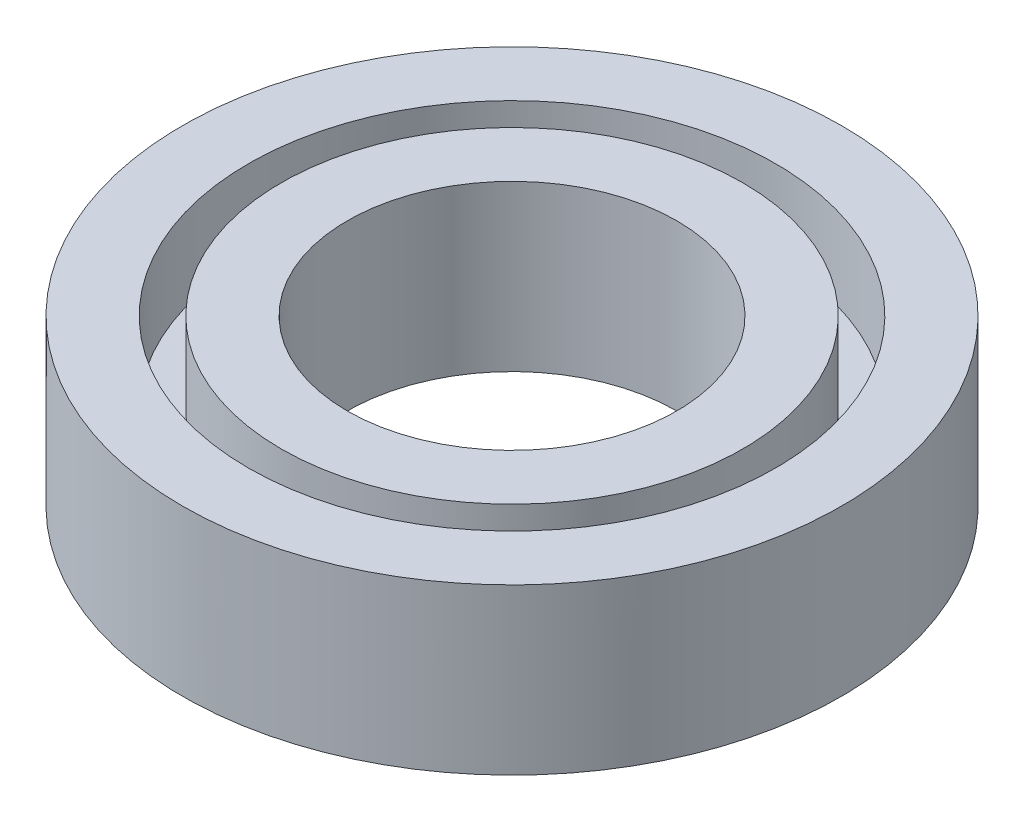
from build123d import *

# Parameters (mm, degrees)
SKETCH1_R           = 4
SKETCH1_R_2         = 2
BOSS_EXTRUDE1_DEPTH = 3
SKETCH2_R           = 3.2
SKETCH2_R_2         = 2.8
CUT_EXTRUDE1_DEPTH  = 1
SKETCH3_R           = 4
SKETCH3_R_2         = 2
CUT_EXTRUDE2_DEPTH  = 1


with BuildPart() as part:
    # Sketch1 → Boss-Extrude1 (new body)
    with BuildSketch(Plane(origin=(0, 0, 0), x_dir=(1, 0, 0), z_dir=(0, 1, 0))):
        Circle(SKETCH1_R)
        Circle(SKETCH1_R_2, mode=Mode.SUBTRACT)
    extrude(amount=BOSS_EXTRUDE1_DEPTH)

    # Sketch2 → Cut-Extrude1 (cut)
    with BuildSketch(Plane(origin=(0, 3, 0), x_dir=(1, 0, 0), z_dir=(0, 1, 0))):
        Circle(SKETCH2_R)
        Circle(SKETCH2_R_2, mode=Mode.SUBTRACT)
    extrude(amount=-CUT_EXTRUDE1_DEPTH, mode=Mode.SUBTRACT)

    # Sketch3 → Cut-Extrude2 (cut)
    with BuildSketch(Plane.XZ):
        Circle(SKETCH3_R)
        Circle(SKETCH3_R_2, mode=Mode.SUBTRACT)
    extrude(amount=-CUT_EXTRUDE2_DEPTH, mode=Mode.SUBTRACT)


solid = part.part
